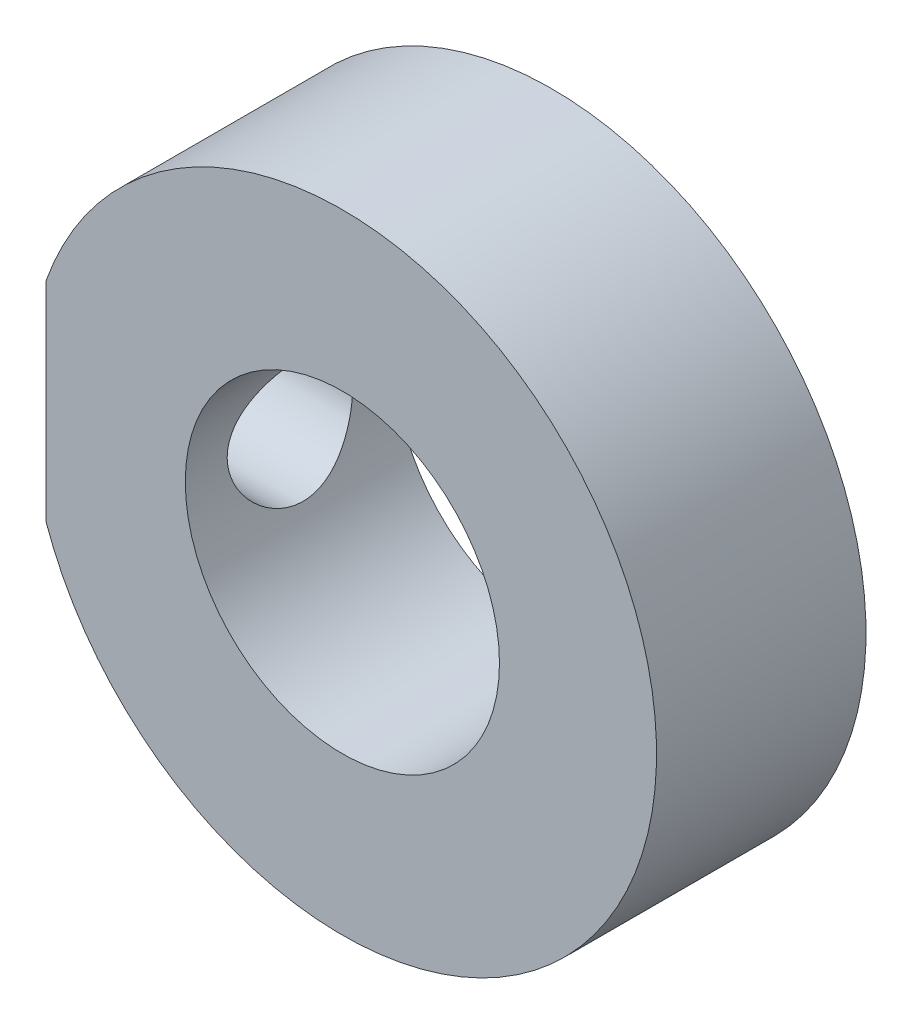
from build123d import *

# Parameters (mm, degrees)
SKIZZE1_R                       = 15
SKIZZE1_R_2                     = 7.5
AUFSATZ_LINEAR_AUSTRAGEN1_DEPTH = 5
SCHNITT_LINEAR_AUSTRAGEN1_DEPTH = 11
SCHNITT_LINEAR_AUSTRAGEN2_REACH = 31.142
SKIZZE3_R                       = 3


with BuildPart() as part:
    # Skizze1 → Aufsatz-Linear austragen1 (new body, symmetric)
    with BuildSketch(Plane.XY):
        Circle(SKIZZE1_R)
        Circle(SKIZZE1_R_2, mode=Mode.SUBTRACT)
    extrude(amount=AUFSATZ_LINEAR_AUSTRAGEN1_DEPTH, both=True)

    # Skizze2 → Schnitt-Linear austragen1 (cut, through all)
    with BuildSketch(Plane.XY.offset(5)):
        with BuildLine():
            Line((-14.142135624, 5), (-14.142135624, -5))
            ThreePointArc((-14.142135624, -5), (-15, 0), (-14.142135624, 5))
        make_face()
    extrude(amount=-SCHNITT_LINEAR_AUSTRAGEN1_DEPTH, mode=Mode.SUBTRACT)

    # Skizze3 → Schnitt-Linear austragen2 (cut, up to next)
    with BuildSketch(Plane.ZY.offset(14.142135624), mode=Mode.PRIVATE) as schnitt_linear_austragen2_sk1:
        Circle(SKIZZE3_R)
    schnitt_linear_austragen2_tool1 = extrude(schnitt_linear_austragen2_sk1.sketch, amount=-SCHNITT_LINEAR_AUSTRAGEN2_REACH, mode=Mode.PRIVATE) & part.part
    add(schnitt_linear_austragen2_tool1.solids().sort_by_distance((-14.142136, 0, 0))[0], mode=Mode.SUBTRACT)


solid = part.part
